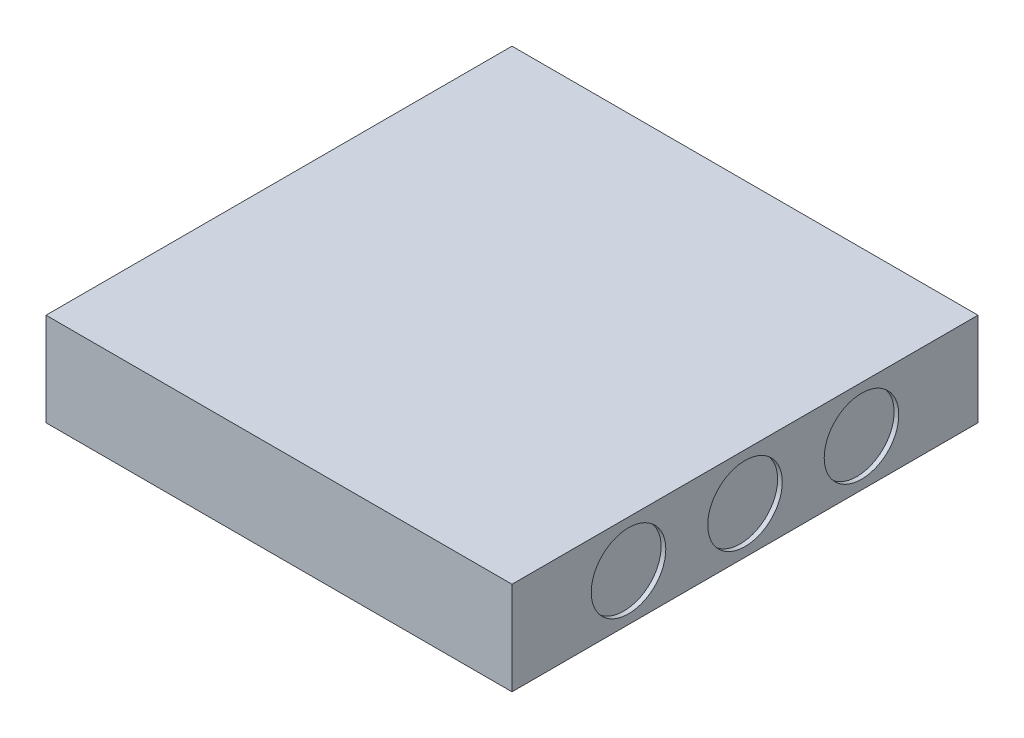
from build123d import *

# Parameters (mm, degrees)
SKETCH1_W           = 50
SKETCH1_H           = 50
BOSS_EXTRUDE1_DEPTH = 10
SKETCH2_W           = 5
SKETCH2_H           = 5
CUT_EXTRUDE1_DEPTH  = 6
SKETCH3_R           = 4
CUT_EXTRUDE2_DEPTH  = 0.5


with BuildPart() as part:
    # Sketch1 → Boss-Extrude1 (new body)
    with BuildSketch(Plane(origin=(0, 0, 0), x_dir=(1, 0, 0), z_dir=(0, 1, 0))):
        Rectangle(SKETCH1_W, SKETCH1_H)
    extrude(amount=BOSS_EXTRUDE1_DEPTH)

    # Sketch2 → Cut-Extrude1 (cut)
    with BuildSketch(Plane.ZY.offset(25)):
        with Locations((0, 5)):
            Rectangle(SKETCH2_W, SKETCH2_H)
    extrude(amount=-CUT_EXTRUDE1_DEPTH, mode=Mode.SUBTRACT)

    # Sketch3 → Cut-Extrude2 (cut)
    with BuildSketch(Plane(origin=(25, 0, 0), x_dir=(0, 0, -1), z_dir=(1, 0, 0))):
        with Locations((-12.5, 5)):
            Circle(SKETCH3_R)
        with Locations((12.5, 5)):
            Circle(SKETCH3_R)
        with Locations((0, 5)):
            Circle(SKETCH3_R)
    extrude(amount=-CUT_EXTRUDE2_DEPTH, mode=Mode.SUBTRACT)


solid = part.part
